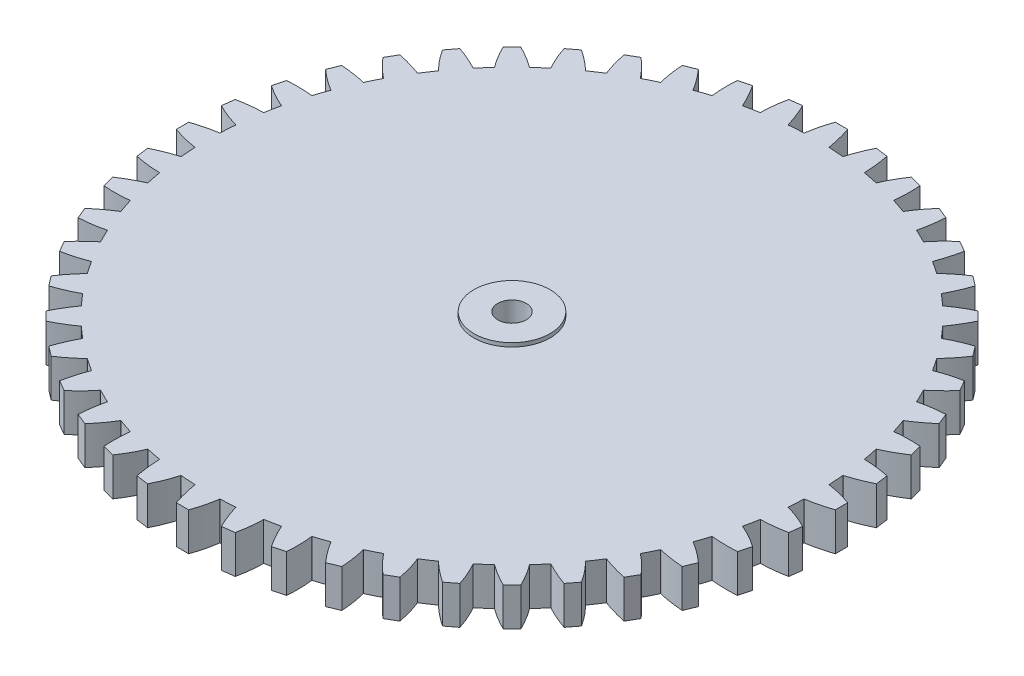
from build123d import *

# Parameters (mm, degrees)
SKETCH1_R                = 16
BOSS_EXTRUDE1_DEPTH      = 2
SKETCH2_R                = 0.75
CUT_EXTRUDE1_DEPTH       = 2
SKETCH3_R                = 2
SKETCH3_R_2              = 0.75
BOSS_EXTRUDE2_DEPTH      = 0.2
BOSS_EXTRUDE2_DEPTH_BACK = 2.2
BOSS_EXTRUDE3_DEPTH      = 2
CIRPATTERN1_COUNT        = 48


with BuildPart() as part:
    # Sketch1 → Boss-Extrude1 (new body)
    with BuildSketch(Plane(origin=(0, 0, 0), x_dir=(1, 0, 0), z_dir=(0, 1, 0))):
        Circle(SKETCH1_R)
    extrude(amount=BOSS_EXTRUDE1_DEPTH)

    # Sketch2 → Cut-Extrude1 (cut)
    with BuildSketch(Plane(origin=(0, 2, 0), x_dir=(1, 0, 0), z_dir=(0, 1, 0))):
        Circle(SKETCH2_R)
    extrude(amount=-CUT_EXTRUDE1_DEPTH, mode=Mode.SUBTRACT)

    # Sketch3 → Boss-Extrude2 (add, two sides)
    with BuildSketch(Plane(origin=(0, 2, 0), x_dir=(1, 0, 0), z_dir=(0, 1, 0))) as boss_extrude2_sk:
        Circle(SKETCH3_R)
        Circle(SKETCH3_R_2, mode=Mode.SUBTRACT)
    extrude(amount=BOSS_EXTRUDE2_DEPTH)
    extrude(boss_extrude2_sk.sketch, amount=-BOSS_EXTRUDE2_DEPTH_BACK)

    # Sketch4 → Boss-Extrude3 (add)
    with BuildSketch(Plane(origin=(0, 2, 0), x_dir=(1, 0, 0), z_dir=(0, 1, 0))):
        with BuildLine():
            Line((-0.325, 17.3), (0.325, 17.3))
            ThreePointArc((0.325, 17.3), (0.514320308, 16.656699228), (0.650056029, 16))
            Line((0.650056029, 16), (0.650056029, 15.986789145))
            ThreePointArc((0.650056029, 15.986789145), (0, 16), (-0.650056029, 15.986789145))
            Line((-0.650056029, 15.986789145), (-0.650056029, 16))
            ThreePointArc((-0.650056029, 16), (-0.519730643, 16.658052045), (-0.325, 17.3))
        make_face()
    boss_extrude3 = extrude(amount=-BOSS_EXTRUDE3_DEPTH)

    # CirPattern1: Boss-Extrude3 ×48 about axis
    cirpattern1_axis = Axis((0, 0, 0), (0, 1, 0))
    for i in range(1, CIRPATTERN1_COUNT):
        add(boss_extrude3.rotate(cirpattern1_axis, i * 360 / CIRPATTERN1_COUNT))


solid = part.part
